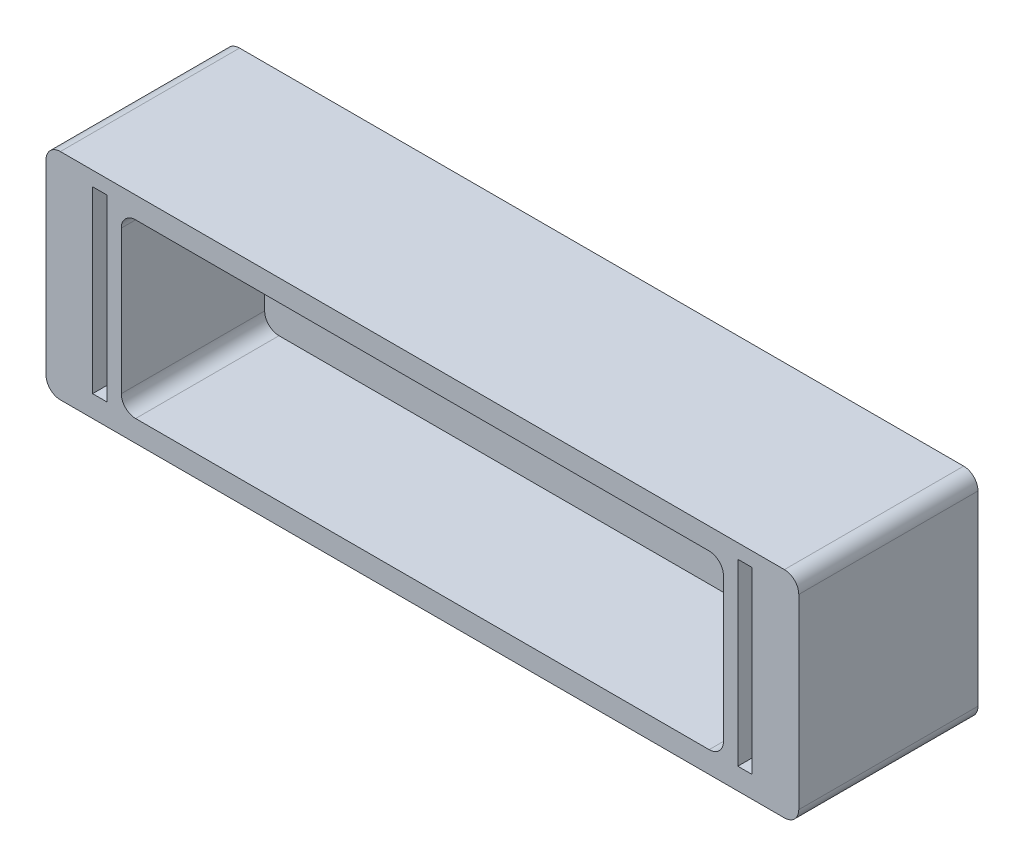
from build123d import *

# Parameters (mm, degrees)
ESQUISSE1_W             = 105
ESQUISSE1_H             = 30
BOSS_EXTRU_1_DEPTH      = 25
ESQUISSE2_W             = 2
ESQUISSE2_H             = 25
ENL_V_MAT_EXTRU_1_DEPTH = 24
CONG_3_R                = 12
CONG_4_R                = 12
ESQUISSE3_W             = 84
ESQUISSE3_H             = 24
ENL_V_MAT_EXTRU_2_DEPTH = 20
CONG_5_R                = 2
CONG_6_R                = 2
CONG_7_R                = 2


with BuildPart() as part:
    # Esquisse1 → Boss.-Extru.1 (new body)
    with BuildSketch(Plane.XY):
        with Locations((10.65403423, 34.547677262)):
            Rectangle(ESQUISSE1_W, ESQUISSE1_H)
    extrude(amount=BOSS_EXTRU_1_DEPTH)

    # Esquisse2 → Enlèv. mat.-Extru.1 (cut)
    with BuildSketch(Plane.XY.offset(25)):
        with Locations((-34.34596577, 35.047677262)):
            Rectangle(ESQUISSE2_W, ESQUISSE2_H)
        with Locations((55.65403423, 35.047677262)):
            Rectangle(ESQUISSE2_W, ESQUISSE2_H)
    extrude(amount=-ENL_V_MAT_EXTRU_1_DEPTH, mode=Mode.SUBTRACT)

    # Congé3
    cong_3_edges = [part.edges().sort_by_distance(p)[0] for p in [
        (55.65403423, 47.547677262, 1),
        (55.65403423, 22.547677262, 1),
    ]]
    fillet(cong_3_edges, radius=CONG_3_R)

    # Congé4
    cong_4_edges = [part.edges().sort_by_distance(p)[0] for p in [
        (-34.34596577, 47.547677262, 1),
        (-34.34596577, 22.547677262, 1),
    ]]
    fillet(cong_4_edges, radius=CONG_4_R)

    # Esquisse3 → Enlèv. mat.-Extru.2 (cut)
    with BuildSketch(Plane.XY.offset(25)):
        with Locations((10.65403423, 34.547677262)):
            Rectangle(ESQUISSE3_W, ESQUISSE3_H)
    extrude(amount=-ENL_V_MAT_EXTRU_2_DEPTH, mode=Mode.SUBTRACT)

    # Congé5
    cong_5_edges = [part.edges().sort_by_distance(p)[0] for p in [
        (52.65403423, 46.547677262, 15),
        (52.65403423, 22.547677262, 15),
        (-41.84596577, 49.547677262, 12.5),
        (63.15403423, 49.547677262, 12.5),
        (63.15403423, 19.547677262, 12.5),
    ]]
    fillet(cong_5_edges, radius=CONG_5_R)

    # Congé6
    cong_6_edges = [part.edges().sort_by_distance(p)[0] for p in [
        (-31.34596577, 22.547677262, 15),
        (-31.34596577, 46.547677262, 15),
    ]]
    fillet(cong_6_edges, radius=CONG_6_R)

    # Congé7
    cong_7_edges = [part.edges().sort_by_distance(p)[0] for p in [
        (-41.84596577, 19.547677262, 12.5),
    ]]
    fillet(cong_7_edges, radius=CONG_7_R)


solid = part.part
